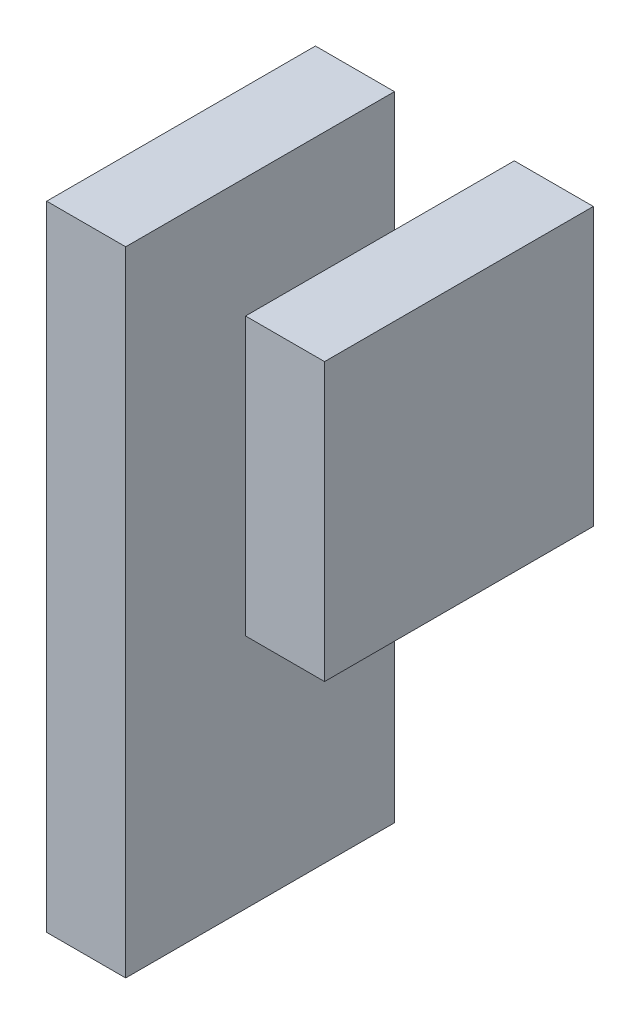
from build123d import *

# Parameters (mm, degrees)
SKIZZE2_W                         = 2.94
SKIZZE2_H                         = 23.5625
AUFSATZ_LINEAR_AUSTRAGEN1_DEPTH   = 10
SKIZZE2_H_2                       = 10.31
AUFSATZ_LINEAR_AUSTRAGEN1_2_DEPTH = 10


with BuildPart() as part:
    # Skizze2 → Aufsatz-Linear austragen1 (new body)
    with BuildSketch(Plane.XY):
        with Locations((149.3025, -66.22375)):
            Rectangle(SKIZZE2_W, SKIZZE2_H)
    extrude(amount=AUFSATZ_LINEAR_AUSTRAGEN1_DEPTH)


with BuildPart() as body_2:
    # Skizze2 → Aufsatz-Linear austragen1 2 (new body)
    with BuildSketch(Plane.XY):
        with Locations((156.7025, -59.5975)):
            Rectangle(SKIZZE2_W, SKIZZE2_H_2)
    extrude(amount=AUFSATZ_LINEAR_AUSTRAGEN1_2_DEPTH)


solid = Compound([part.part, body_2.part])
